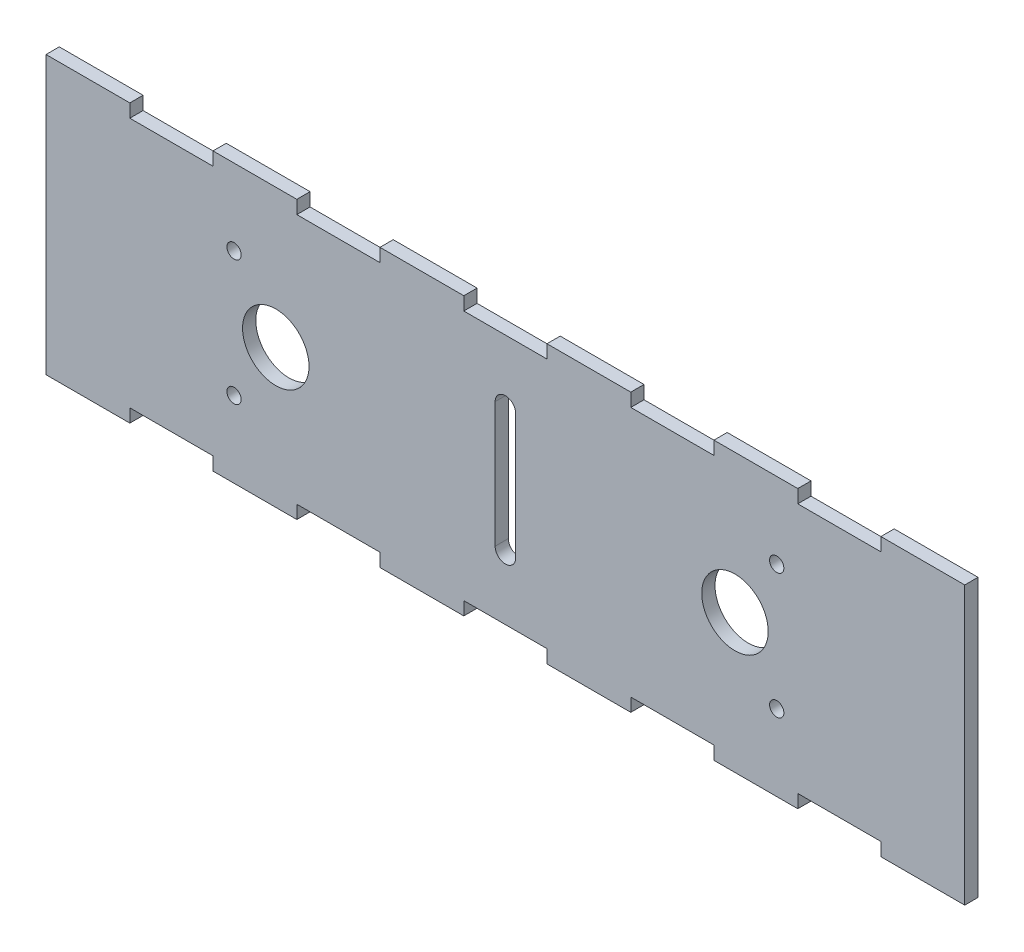
from build123d import *

# Parameters (mm, degrees)
SKETCH1_R           = 1.755
SKETCH1_R_2         = 8
BOSS_EXTRUDE1_DEPTH = 3.175
SKETCH2_R           = 7.95936
SKETCH2_R_2         = 1.71436
BOSS_EXTRUDE2_DEPTH = 3.175


with BuildPart() as part:
    # Sketch1 → Boss-Extrude1 (new body)
    with BuildSketch(Plane.XY):
        Polygon((-50, 30), (-50, 33.175), (-70, 33.175), (-70, 30), (-90, 30), (-90, 33.175), (-110, 33.175), (-110, -33.175), (-90, -33.175), (-90, -30), (-70, -30), (-70, -33.175), (-50, -33.175), (-50, -30), (-30, -30), (-30, -33.175), (-10, -33.175), (-10, -30), (10, -30), (10, -33.175), (30, -33.175), (30, -30), (50, -30), (50, -33.175), (70, -33.175), (70, -30), (90, -30), (90, -33.175), (110, -33.175), (110, 33.175), (90, 33.175), (90, 30), (70, 30), (70, 33.175), (50, 33.175), (50, 30), (30, 30), (30, 33.175), (10, 33.175), (10, 30), (-10, 30), (-10, 33.175), (-30, 33.175), (-30, 30), align=None)
        with Locations((-65, -15)):
            Circle(SKETCH1_R, mode=Mode.SUBTRACT)
        with Locations((65, -15)):
            Circle(SKETCH1_R, mode=Mode.SUBTRACT)
        with Locations((-65, 15)):
            Circle(SKETCH1_R, mode=Mode.SUBTRACT)
        with Locations((-55, 0)):
            Circle(SKETCH1_R_2, mode=Mode.SUBTRACT)
        with BuildLine():
            ThreePointArc((2.5, -15), (0, -17.5), (-2.5, -15))
            Line((-2.5, -15), (-2.5, 15))
            ThreePointArc((-2.5, 15), (0, 17.5), (2.5, 15))
            Line((2.5, 15), (2.5, -15))
        make_face(mode=Mode.SUBTRACT)
        with Locations((55, 0)):
            Circle(SKETCH1_R_2, mode=Mode.SUBTRACT)
        with Locations((65, 15)):
            Circle(SKETCH1_R, mode=Mode.SUBTRACT)
    extrude(amount=BOSS_EXTRUDE1_DEPTH)

    # Sketch2 → Boss-Extrude2 (add)
    with BuildSketch(Plane.XY.offset(3.175)):
        Polygon((110.04064, -33.21564), (110.04064, 33.21564), (89.95936, 33.21564), (89.95936, 30.04064), (70.04064, 30.04064), (70.04064, 33.21564), (49.95936, 33.21564), (49.95936, 30.04064), (30.04064, 30.04064), (30.04064, 33.21564), (9.95936, 33.21564), (9.95936, 30.04064), (-9.95936, 30.04064), (-9.95936, 33.21564), (-30.04064, 33.21564), (-30.04064, 30.04064), (-49.95936, 30.04064), (-49.95936, 33.21564), (-70.04064, 33.21564), (-70.04064, 30.04064), (-89.95936, 30.04064), (-89.95936, 33.21564), (-110.04064, 33.21564), (-110.04064, -33.21564), (-89.95936, -33.21564), (-89.95936, -30.04064), (-70.04064, -30.04064), (-70.04064, -33.21564), (-49.95936, -33.21564), (-49.95936, -30.04064), (-30.04064, -30.04064), (-30.04064, -33.21564), (-9.95936, -33.21564), (-9.95936, -30.04064), (9.95936, -30.04064), (9.95936, -33.21564), (30.04064, -33.21564), (30.04064, -30.04064), (49.95936, -30.04064), (49.95936, -33.21564), (70.04064, -33.21564), (70.04064, -30.04064), (89.95936, -30.04064), (89.95936, -33.21564), align=None)
        with Locations((-55, 0)):
            Circle(SKETCH2_R, mode=Mode.SUBTRACT)
        with Locations((-65, 15)):
            Circle(SKETCH2_R_2, mode=Mode.SUBTRACT)
        with Locations((-65, -15)):
            Circle(SKETCH2_R_2, mode=Mode.SUBTRACT)
        with Locations((55, 0)):
            Circle(SKETCH2_R, mode=Mode.SUBTRACT)
        with Locations((65, 15)):
            Circle(SKETCH2_R_2, mode=Mode.SUBTRACT)
        with Locations((65, -15)):
            Circle(SKETCH2_R_2, mode=Mode.SUBTRACT)
        with BuildLine():
            Line((2.45936, -15), (2.45936, 15))
            ThreePointArc((2.45936, 15), (0, 17.45936), (-2.45936, 15))
            Line((-2.45936, 15), (-2.45936, -15))
            ThreePointArc((-2.45936, -15), (0, -17.45936), (2.45936, -15))
        make_face(mode=Mode.SUBTRACT)
    extrude(amount=-BOSS_EXTRUDE2_DEPTH)


solid = part.part
